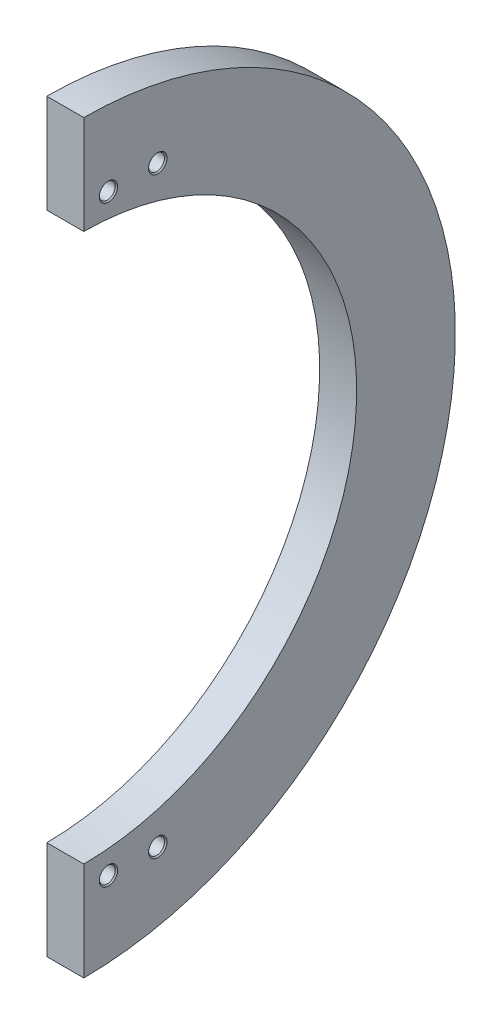
from build123d import *

# Parameters (mm, degrees)
SKETCH1_W                         = 19.05
SKETCH1_H                         = 50.8
REVOLVE_THIN1_ANGLE               = 180
SKETCH81_W                        = 0.5
SKETCH81_H                        = 430
EXTRUDE1_DEPTH                    = 20.05
F_5_16_CLEARANCE_HOLE1_AT_2_COUNT = 2
F_5_16_CLEARANCE_HOLE1_AT_2_PITCH = 25.4
F_5_16_CLEARANCE_HOLE1_AT_3_COUNT = 2
F_5_16_CLEARANCE_HOLE1_AT_3_PITCH = 304.8
F_5_16_CLEARANCE_HOLE1_AT_4_COUNT = 2
F_5_16_CLEARANCE_HOLE1_AT_4_PITCH = 305.856502301


with BuildPart() as part:
    # Sketch1 → Revolve-Thin1 (revolve)
    with BuildSketch(Plane.XY):
        with Locations((9.525, 166.3625)):
            Rectangle(SKETCH1_W, SKETCH1_H)
    revolve(axis=Axis((0, 0, 0), (-1, 0, 0)), revolution_arc=REVOLVE_THIN1_ANGLE)

    # Sketch81 → Extrude1 (cut, through all)
    with BuildSketch(Plane(origin=(0, 0, 0), x_dir=(0, 0, -1), z_dir=(1, 0, 0))):
        with Locations((0.25, 0)):
            Rectangle(SKETCH81_W, SKETCH81_H)
    extrude(amount=EXTRUDE1_DEPTH, mode=Mode.SUBTRACT)

    # Sketch82 → 5_16 Clearance Hole1 (revolve, cut)
    with BuildSketch(Plane(origin=(19.05, 152.4, -38.6), x_dir=(0, 0, -1), z_dir=(0, 1, 0))):
        Polygon((0, 0), (0, 19.05), (4.7371, 19.05), (4.1021, 18.415), (4.1021, 0.635), (4.7371, 0), align=None)
    f_5_16_clearance_hole1 = revolve(axis=Axis((25.4, 152.4, -38.6), (-1, 0, 0)), mode=Mode.SUBTRACT)

    # 5_16 Clearance Hole1 at 2: 5_16 Clearance Hole1 ×2
    with Locations(*[(0, 0, i * F_5_16_CLEARANCE_HOLE1_AT_2_PITCH) for i in range(1, F_5_16_CLEARANCE_HOLE1_AT_2_COUNT)]):
        add(f_5_16_clearance_hole1, mode=Mode.SUBTRACT)

    # 5_16 Clearance Hole1 at 3: 5_16 Clearance Hole1 ×2
    with Locations(*[(0, -i * F_5_16_CLEARANCE_HOLE1_AT_3_PITCH, 0) for i in range(1, F_5_16_CLEARANCE_HOLE1_AT_3_COUNT)]):
        add(f_5_16_clearance_hole1, mode=Mode.SUBTRACT)

    # 5_16 Clearance Hole1 at 4: 5_16 Clearance Hole1 ×2
    with Locations(*[Vector(0, -0.996545758, 0.08304548) * (i * F_5_16_CLEARANCE_HOLE1_AT_4_PITCH) for i in range(1, F_5_16_CLEARANCE_HOLE1_AT_4_COUNT)]):
        add(f_5_16_clearance_hole1, mode=Mode.SUBTRACT)


solid = part.part
